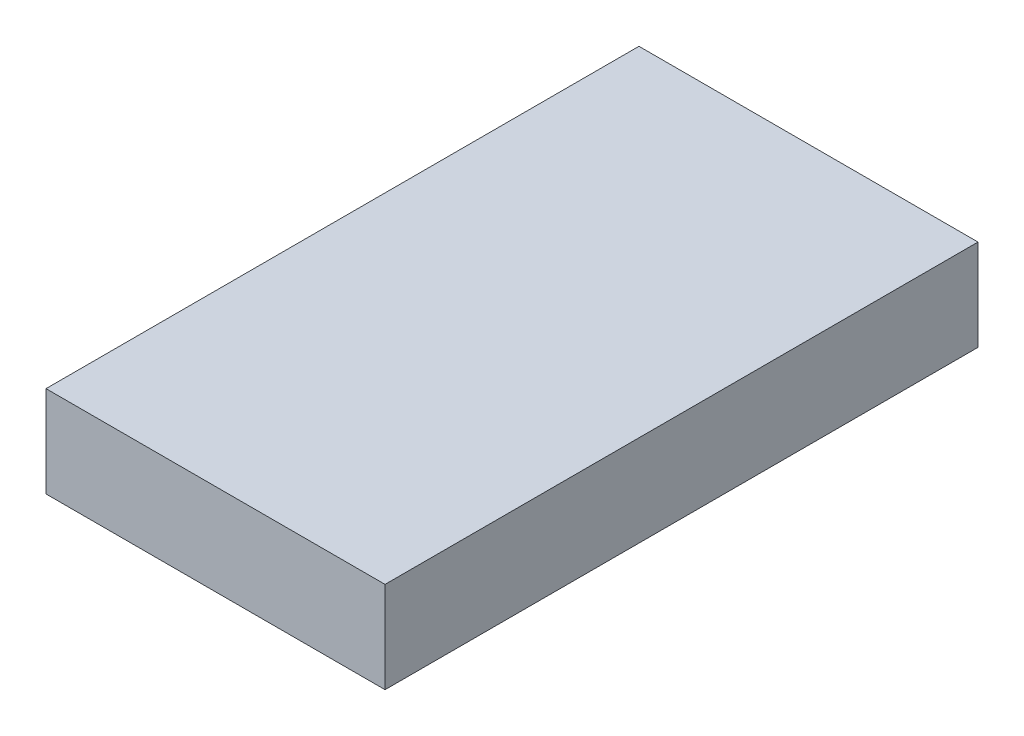
from build123d import *

# Parameters (mm, degrees)
SKETCH_1_W      = 22.3
SKETCH_1_H      = 39
EXTRUDE_1_DEPTH = 6


with BuildPart() as part:
    # 草图1 → 凸台-拉伸1 (new body)
    with BuildSketch(Plane(origin=(0, 0, 0), x_dir=(1, 0, 0), z_dir=(0, 1, 0))):
        with Locations((11.15, -19.5)):
            Rectangle(SKETCH_1_W, SKETCH_1_H)
    extrude(amount=EXTRUDE_1_DEPTH)


solid = part.part
